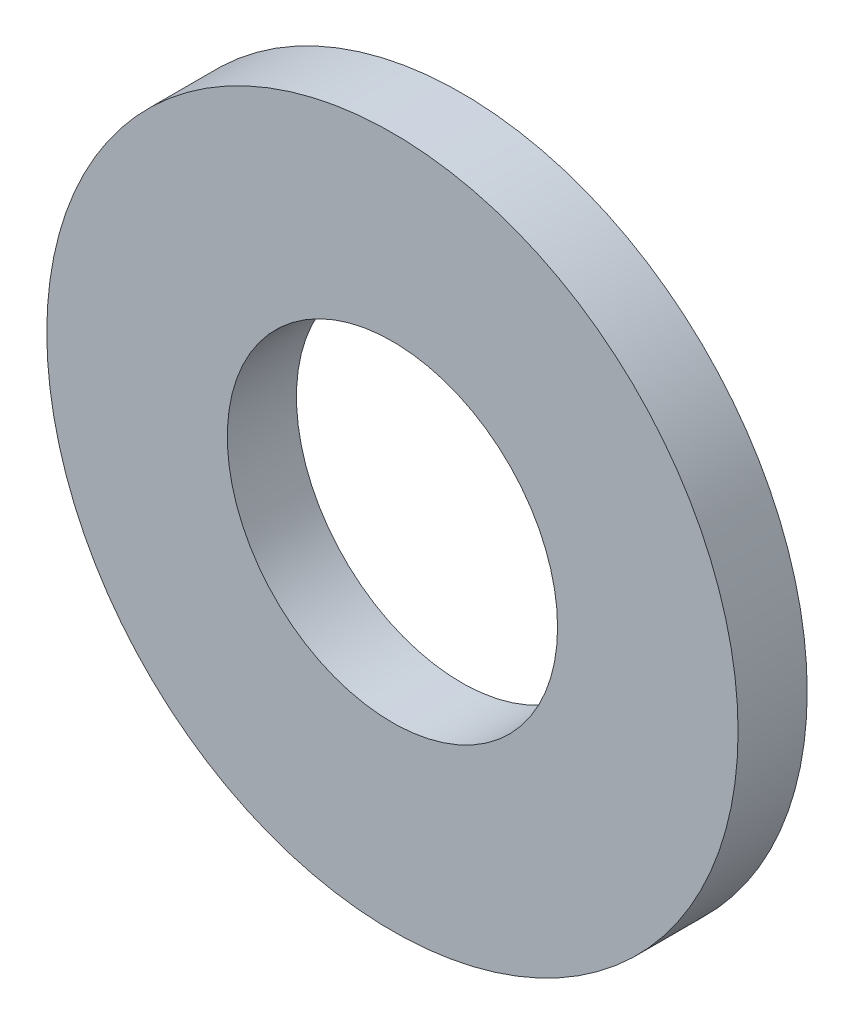
from build123d import *

# Parameters (mm, degrees)
SKETCH1_R           = 4.5
SKETCH1_R_2         = 2.15
BOSS_EXTRUDE1_DEPTH = 0.9


with BuildPart() as part:
    # Sketch1 → Boss-Extrude1 (new body)
    with BuildSketch(Plane.XY):
        Circle(SKETCH1_R)
        Circle(SKETCH1_R_2, mode=Mode.SUBTRACT)
    extrude(amount=BOSS_EXTRUDE1_DEPTH)


solid = part.part
